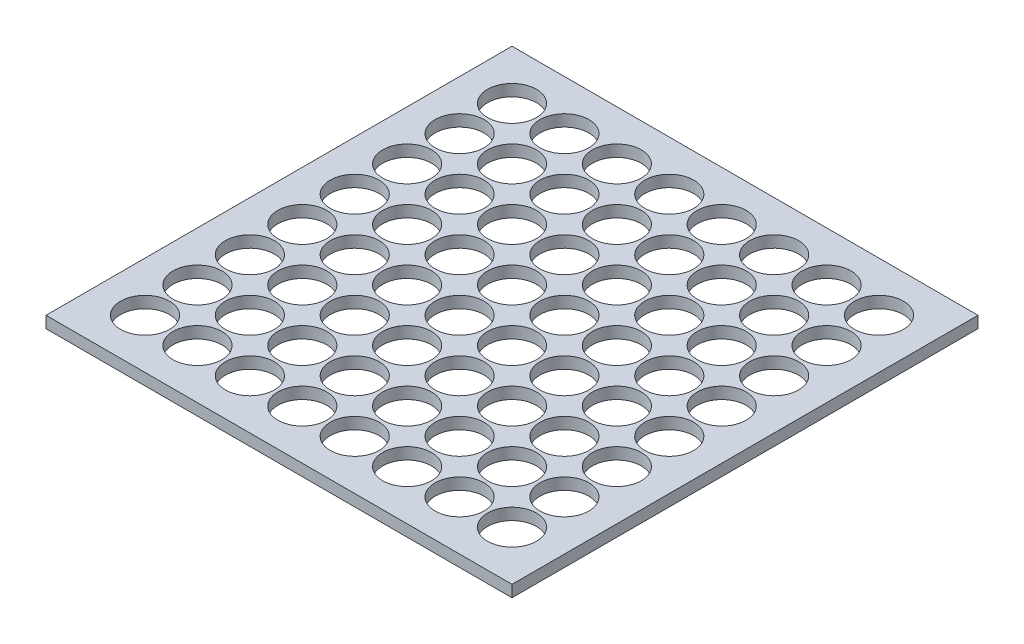
from build123d import *

# Parameters (mm, degrees)
SKETCH1_W           = 400
SKETCH1_H           = 400
SKETCH1_R           = 21
BOSS_EXTRUDE1_DEPTH = 10


with BuildPart() as part:
    # Sketch1 → Boss-Extrude1 (new body)
    with BuildSketch(Plane(origin=(0, 0, 0), x_dir=(1, 0, 0), z_dir=(0, 1, 0))):
        Rectangle(SKETCH1_W, SKETCH1_H)
        with Locations((-157.5, 157.5)):
            Circle(SKETCH1_R, mode=Mode.SUBTRACT)
        with Locations((-112.5, 157.5)):
            Circle(SKETCH1_R, mode=Mode.SUBTRACT)
        with Locations((-67.5, 157.5)):
            Circle(SKETCH1_R, mode=Mode.SUBTRACT)
        with Locations((67.5, 157.5)):
            Circle(SKETCH1_R, mode=Mode.SUBTRACT)
        with Locations((22.5, 157.5)):
            Circle(SKETCH1_R, mode=Mode.SUBTRACT)
        with Locations((-22.5, 157.5)):
            Circle(SKETCH1_R, mode=Mode.SUBTRACT)
        with Locations((112.5, 157.5)):
            Circle(SKETCH1_R, mode=Mode.SUBTRACT)
        with Locations((157.5, 157.5)):
            Circle(SKETCH1_R, mode=Mode.SUBTRACT)
        with Locations((157.5, 112.5)):
            Circle(SKETCH1_R, mode=Mode.SUBTRACT)
        with Locations((112.5, 112.5)):
            Circle(SKETCH1_R, mode=Mode.SUBTRACT)
        with Locations((-22.5, 112.5)):
            Circle(SKETCH1_R, mode=Mode.SUBTRACT)
        with Locations((22.5, 112.5)):
            Circle(SKETCH1_R, mode=Mode.SUBTRACT)
        with Locations((67.5, 112.5)):
            Circle(SKETCH1_R, mode=Mode.SUBTRACT)
        with Locations((-67.5, 112.5)):
            Circle(SKETCH1_R, mode=Mode.SUBTRACT)
        with Locations((-112.5, 112.5)):
            Circle(SKETCH1_R, mode=Mode.SUBTRACT)
        with Locations((-157.5, 112.5)):
            Circle(SKETCH1_R, mode=Mode.SUBTRACT)
        with Locations((-157.5, 67.5)):
            Circle(SKETCH1_R, mode=Mode.SUBTRACT)
        with Locations((-112.5, 67.5)):
            Circle(SKETCH1_R, mode=Mode.SUBTRACT)
        with Locations((-67.5, 67.5)):
            Circle(SKETCH1_R, mode=Mode.SUBTRACT)
        with Locations((67.5, 67.5)):
            Circle(SKETCH1_R, mode=Mode.SUBTRACT)
        with Locations((22.5, 67.5)):
            Circle(SKETCH1_R, mode=Mode.SUBTRACT)
        with Locations((-22.5, 67.5)):
            Circle(SKETCH1_R, mode=Mode.SUBTRACT)
        with Locations((112.5, 67.5)):
            Circle(SKETCH1_R, mode=Mode.SUBTRACT)
        with Locations((157.5, 67.5)):
            Circle(SKETCH1_R, mode=Mode.SUBTRACT)
        with Locations((157.5, 22.5)):
            Circle(SKETCH1_R, mode=Mode.SUBTRACT)
        with Locations((112.5, 22.5)):
            Circle(SKETCH1_R, mode=Mode.SUBTRACT)
        with Locations((-22.5, 22.5)):
            Circle(SKETCH1_R, mode=Mode.SUBTRACT)
        with Locations((22.5, 22.5)):
            Circle(SKETCH1_R, mode=Mode.SUBTRACT)
        with Locations((67.5, 22.5)):
            Circle(SKETCH1_R, mode=Mode.SUBTRACT)
        with Locations((-67.5, 22.5)):
            Circle(SKETCH1_R, mode=Mode.SUBTRACT)
        with Locations((-112.5, 22.5)):
            Circle(SKETCH1_R, mode=Mode.SUBTRACT)
        with Locations((-157.5, 22.5)):
            Circle(SKETCH1_R, mode=Mode.SUBTRACT)
        with Locations((-157.5, -22.5)):
            Circle(SKETCH1_R, mode=Mode.SUBTRACT)
        with Locations((-112.5, -22.5)):
            Circle(SKETCH1_R, mode=Mode.SUBTRACT)
        with Locations((-67.5, -22.5)):
            Circle(SKETCH1_R, mode=Mode.SUBTRACT)
        with Locations((67.5, -22.5)):
            Circle(SKETCH1_R, mode=Mode.SUBTRACT)
        with Locations((22.5, -22.5)):
            Circle(SKETCH1_R, mode=Mode.SUBTRACT)
        with Locations((-22.5, -22.5)):
            Circle(SKETCH1_R, mode=Mode.SUBTRACT)
        with Locations((112.5, -22.5)):
            Circle(SKETCH1_R, mode=Mode.SUBTRACT)
        with Locations((157.5, -22.5)):
            Circle(SKETCH1_R, mode=Mode.SUBTRACT)
        with Locations((157.5, -67.5)):
            Circle(SKETCH1_R, mode=Mode.SUBTRACT)
        with Locations((112.5, -67.5)):
            Circle(SKETCH1_R, mode=Mode.SUBTRACT)
        with Locations((-22.5, -67.5)):
            Circle(SKETCH1_R, mode=Mode.SUBTRACT)
        with Locations((22.5, -67.5)):
            Circle(SKETCH1_R, mode=Mode.SUBTRACT)
        with Locations((67.5, -67.5)):
            Circle(SKETCH1_R, mode=Mode.SUBTRACT)
        with Locations((-67.5, -67.5)):
            Circle(SKETCH1_R, mode=Mode.SUBTRACT)
        with Locations((-112.5, -67.5)):
            Circle(SKETCH1_R, mode=Mode.SUBTRACT)
        with Locations((-157.5, -67.5)):
            Circle(SKETCH1_R, mode=Mode.SUBTRACT)
        with Locations((-157.5, -112.5)):
            Circle(SKETCH1_R, mode=Mode.SUBTRACT)
        with Locations((-112.5, -112.5)):
            Circle(SKETCH1_R, mode=Mode.SUBTRACT)
        with Locations((-67.5, -112.5)):
            Circle(SKETCH1_R, mode=Mode.SUBTRACT)
        with Locations((67.5, -112.5)):
            Circle(SKETCH1_R, mode=Mode.SUBTRACT)
        with Locations((22.5, -112.5)):
            Circle(SKETCH1_R, mode=Mode.SUBTRACT)
        with Locations((-22.5, -112.5)):
            Circle(SKETCH1_R, mode=Mode.SUBTRACT)
        with Locations((112.5, -112.5)):
            Circle(SKETCH1_R, mode=Mode.SUBTRACT)
        with Locations((157.5, -112.5)):
            Circle(SKETCH1_R, mode=Mode.SUBTRACT)
        with Locations((157.5, -157.5)):
            Circle(SKETCH1_R, mode=Mode.SUBTRACT)
        with Locations((112.5, -157.5)):
            Circle(SKETCH1_R, mode=Mode.SUBTRACT)
        with Locations((-22.5, -157.5)):
            Circle(SKETCH1_R, mode=Mode.SUBTRACT)
        with Locations((22.5, -157.5)):
            Circle(SKETCH1_R, mode=Mode.SUBTRACT)
        with Locations((67.5, -157.5)):
            Circle(SKETCH1_R, mode=Mode.SUBTRACT)
        with Locations((-67.5, -157.5)):
            Circle(SKETCH1_R, mode=Mode.SUBTRACT)
        with Locations((-112.5, -157.5)):
            Circle(SKETCH1_R, mode=Mode.SUBTRACT)
        with Locations((-157.5, -157.5)):
            Circle(SKETCH1_R, mode=Mode.SUBTRACT)
    extrude(amount=BOSS_EXTRUDE1_DEPTH)


solid = part.part
